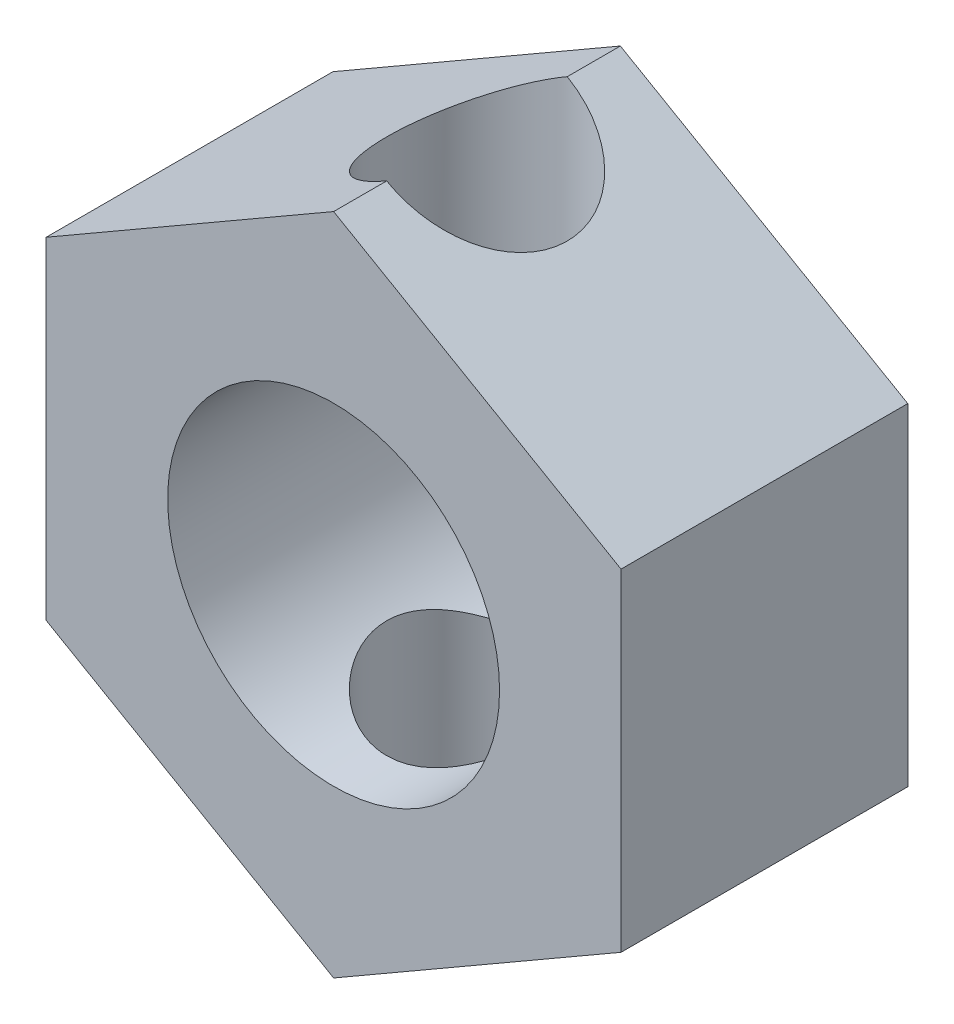
from build123d import *

# Parameters (mm, degrees)
SKETCH1_R          = 3.175
EXTRUDE1_DEPTH     = 5.4864
CUT_EXTRUDE1_START = -6.349814
SKETCH2_R          = 1.7272
CUT_EXTRUDE1_DEPTH = 12.699628


with BuildPart() as part:
    # Sketch1 → Extrude1 (new body)
    with BuildSketch(Plane.XY):
        Polygon((0, 6.349813731), (-5.4991, 3.174906865), (-5.4991, -3.174906865), (0, -6.349813731), (5.4991, -3.174906865), (5.4991, 3.174906865), align=None)
        Circle(SKETCH1_R, mode=Mode.SUBTRACT)
    extrude(amount=EXTRUDE1_DEPTH)

    # Sketch2 → Cut-Extrude1 (cut)
    with BuildSketch(Plane(origin=(0, 0, 0), x_dir=(0, 0, -1), z_dir=(0, 1, 0)).offset(CUT_EXTRUDE1_START)):
        with Locations((-2.7432, 0)):
            Circle(SKETCH2_R)
    extrude(amount=CUT_EXTRUDE1_DEPTH, mode=Mode.SUBTRACT)


solid = part.part
